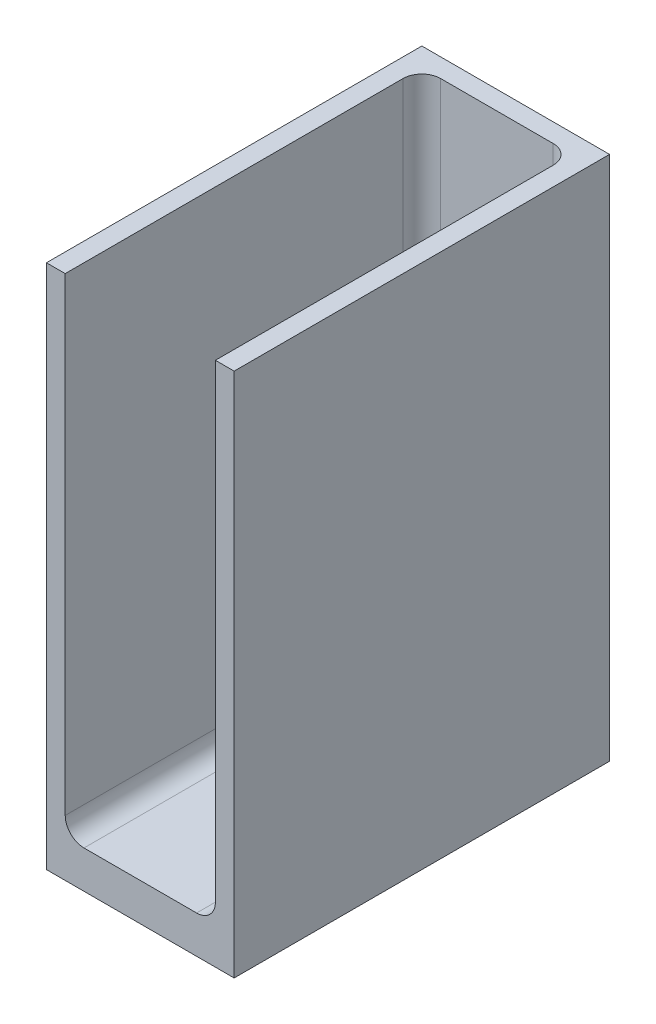
from build123d import *

# Parameters (mm, degrees)
SKETCH1_W           = 25.4
SKETCH1_H           = 50.8
BOSS_EXTRUDE1_DEPTH = 5.08
BOSS_EXTRUDE2_DEPTH = 66.04
FILLET1_R           = 2.54


with BuildPart() as part:
    # Sketch1 → Boss-Extrude1 (new body)
    with BuildSketch(Plane(origin=(0, 0, 0), x_dir=(1, 0, 0), z_dir=(0, 1, 0))):
        Rectangle(SKETCH1_W, SKETCH1_H)
    extrude(amount=BOSS_EXTRUDE1_DEPTH)

    # Sketch2 → Boss-Extrude2 (add)
    with BuildSketch(Plane(origin=(0, 5.08, 0), x_dir=(1, 0, 0), z_dir=(0, 1, 0))):
        Polygon((-12.7, -25.4), (-12.7, 25.4), (12.7, 25.4), (12.7, -25.4), (10.16, -25.4), (10.16, 22.86), (-10.16, 22.86), (-10.16, -25.4), align=None)
    extrude(amount=BOSS_EXTRUDE2_DEPTH)

    # Fillet1
    fillet1_edges = [part.edges().sort_by_distance(p)[0] for p in [
        (-10.16, 5.08, 1.27),
        (0, 5.08, -22.86),
        (-10.16, 38.1, -22.86),
        (10.16, 5.08, 1.27),
        (10.16, 38.1, -22.86),
    ]]
    fillet(fillet1_edges, radius=FILLET1_R)


solid = part.part
